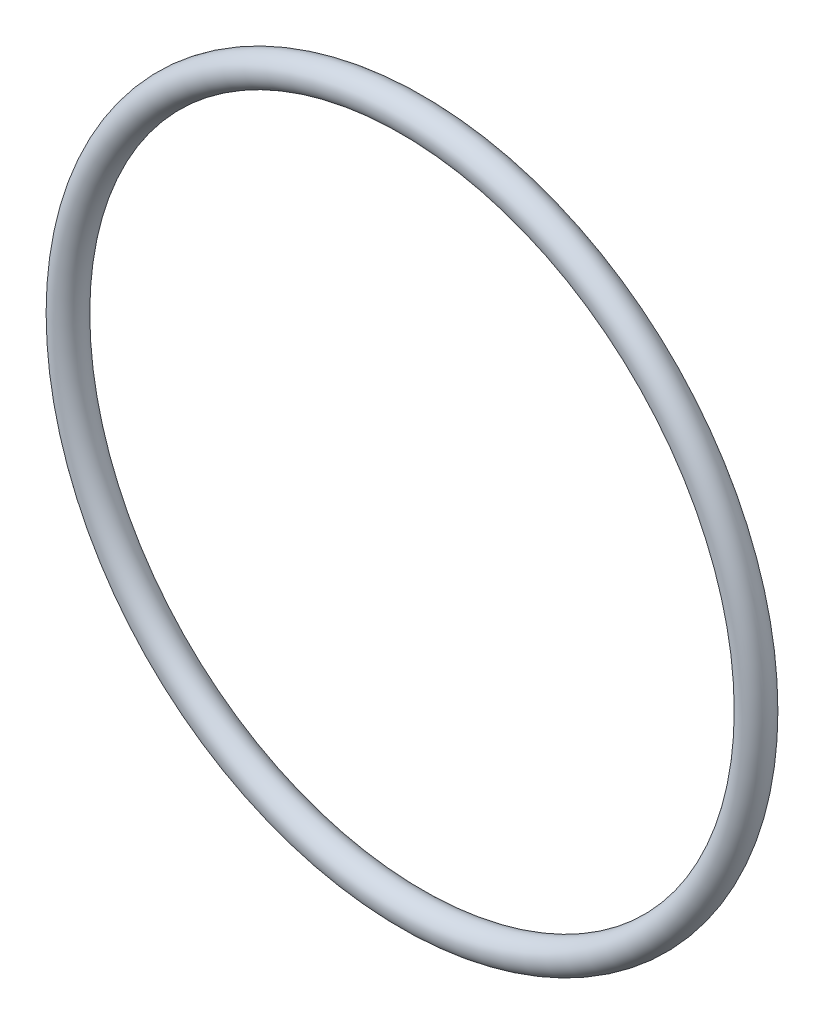
from build123d import *

# Parameters (mm, degrees)
SKETCH1_R = 0.889


with BuildPart() as part:
    # Sketch1 → Revolve1 (revolve)
    with BuildSketch(Plane(origin=(0, 0, 0), x_dir=(0, -1, 0), z_dir=(1, 0, 0))):
        with Locations((19.7993, 0)):
            Circle(SKETCH1_R)
    revolve(axis=Axis((0, 0, 0.889), (0, 0, -1)))


solid = part.part
